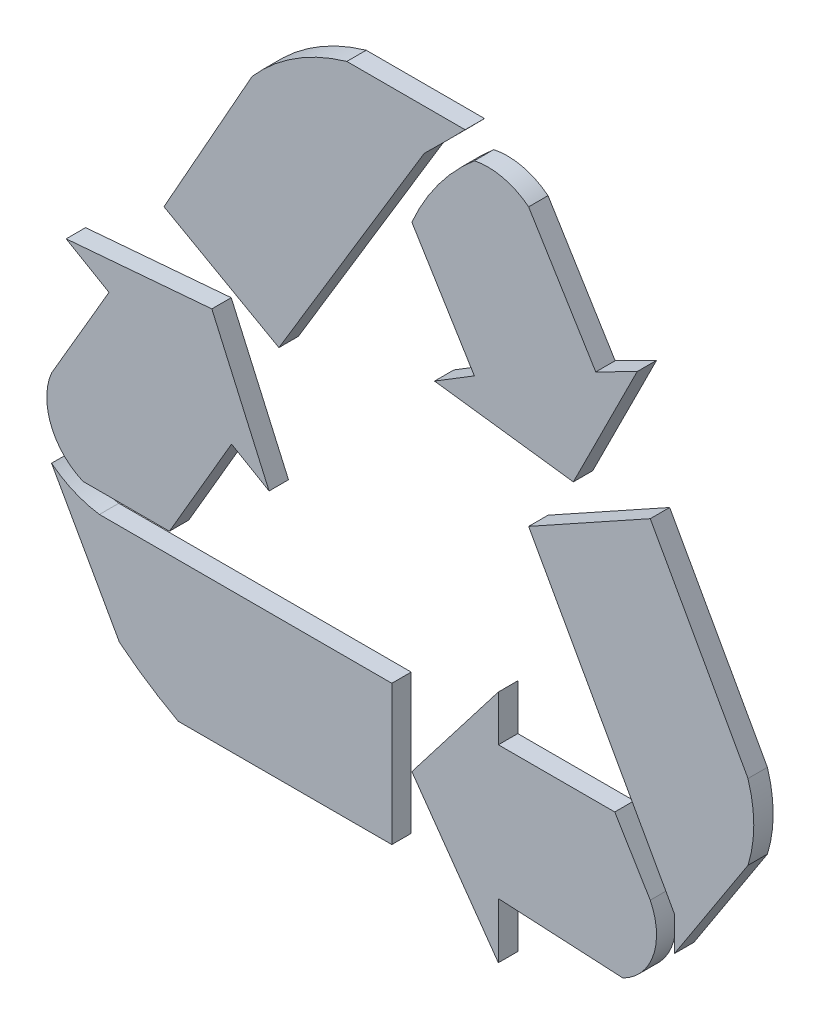
from build123d import *

# Parameters (mm, degrees)
BOSS_EXTRUDE1_DEPTH   = 0.254
BOSS_EXTRUDE1_2_DEPTH = 0.254
BOSS_EXTRUDE1_3_DEPTH = 0.254
BOSS_EXTRUDE1_4_DEPTH = 0.254
BOSS_EXTRUDE1_5_DEPTH = 0.254
BOSS_EXTRUDE1_6_DEPTH = 0.254


with BuildPart() as part:
    # Sketch1 → Boss-Extrude1 (new body)
    with BuildSketch(Plane.XY):
        with BuildLine():
            Line((5.637000935, 11.943781458), (7.185995863, 11.943781458))
            ThreePointArc((7.185995863, 11.943781458), (6.919891183, 11.674778799), (6.650888524, 11.408674119))
            Line((6.650888524, 11.408674119), (4.747952976, 8.254071924))
            Line((4.747952976, 8.254071924), (3.243099683, 9.0992635))
            Line((3.243099683, 9.0992635), (4.397804993, 11.155202222))
            ThreePointArc((4.397804993, 11.155202222), (4.960721662, 11.638562457), (5.637000935, 11.943781458))
        make_face()
    extrude(amount=BOSS_EXTRUDE1_DEPTH)


with BuildPart() as body_2:
    # Sketch1 → Boss-Extrude1 2 (new body)
    with BuildSketch(Plane.XY):
        with BuildLine():
            Line((6.48874249, 10.5468587), (7.307105521, 9.213267603))
            Line((7.307105521, 9.213267603), (6.785548208, 8.893212059))
            Line((6.785548208, 8.893212059), (8.603076052, 8.658733216))
            Line((8.603076052, 8.658733216), (9.439062626, 10.328298615))
            Line((9.439062626, 10.328298615), (8.89668655, 10.052613091))
            Line((8.89668655, 10.052613091), (8.017649291, 11.485077924))
            ThreePointArc((8.017649291, 11.485077924), (7.681060328, 11.64807643), (7.307105521, 11.652371198))
            ThreePointArc((7.307105521, 11.652371198), (6.834746968, 11.146382174), (6.48874249, 10.5468587))
        make_face()
    extrude(amount=BOSS_EXTRUDE1_2_DEPTH)


with BuildPart() as body_3:
    # Sketch1 → Boss-Extrude1 3 (new body)
    with BuildSketch(Plane.XY):
        with BuildLine():
            Line((8.017649291, 7.861746009), (9.610046163, 8.745368466))
            Line((9.610046163, 8.745368466), (10.889800345, 6.439093267))
            ThreePointArc((10.889800345, 6.439093267), (10.965604743, 5.946852431), (10.889800345, 5.454611596))
            Line((10.889800345, 5.454611596), (9.927748084, 3.973263118))
            Line((9.927748084, 3.973263118), (9.927748084, 4.419511916))
            Line((9.927748084, 4.419511916), (8.017649291, 7.861746009))
        make_face()
    extrude(amount=BOSS_EXTRUDE1_3_DEPTH)


with BuildPart() as body_4:
    # Sketch1 → Boss-Extrude1 4 (new body)
    with BuildSketch(Plane.XY):
        with BuildLine():
            Line((7.621464325, 5.187129092), (9.145128923, 5.187129092))
            Line((9.145128923, 5.187129092), (9.610046163, 4.419511916))
            ThreePointArc((9.610046163, 4.419511916), (9.650762974, 3.814407191), (9.251680452, 3.357742403))
            Line((9.251680452, 3.357742403), (7.621464325, 3.443237722))
            Line((7.621464325, 3.443237722), (7.621464325, 2.715572638))
            Line((7.621464325, 2.715572638), (6.48874249, 4.316477857))
            Line((6.48874249, 4.316477857), (7.621464325, 5.785785902))
            Line((7.621464325, 5.785785902), (7.621464325, 5.187129092))
        make_face()
    extrude(amount=BOSS_EXTRUDE1_4_DEPTH)


with BuildPart() as body_5:
    # Sketch1 → Boss-Extrude1 5 (new body)
    with BuildSketch(Plane.XY):
        with BuildLine():
            Line((1.962512056, 8.094982994), (3.869542298, 8.254071924))
            Line((3.869542298, 8.254071924), (4.619508312, 6.563952326))
            Line((4.619508312, 6.563952326), (4.12815791, 6.850481717))
            Line((4.12815791, 6.850481717), (3.314160785, 5.454611596))
            Line((3.314160785, 5.454611596), (2.182778024, 5.454611596))
            ThreePointArc((2.182778024, 5.454611596), (1.764914266, 5.881076175), (1.770995964, 6.478106467))
            Line((1.770995964, 6.478106467), (2.523203463, 7.768017622))
            Line((2.523203463, 7.768017622), (1.962512056, 8.094982994))
        make_face()
    extrude(amount=BOSS_EXTRUDE1_5_DEPTH)


with BuildPart() as body_6:
    # Sketch1 → Boss-Extrude1 6 (new body)
    with BuildSketch(Plane.XY):
        with BuildLine():
            Line((6.226223733, 5.187129092), (6.226223733, 3.357742403))
            Line((6.226223733, 3.357742403), (3.430797167, 3.357742403))
            ThreePointArc((3.430797167, 3.357742403), (3.03357937, 3.595122118), (2.660195359, 3.868463459))
            Line((2.660195359, 3.868463459), (1.770995964, 5.454611596))
            ThreePointArc((1.770995964, 5.454611596), (2.066843427, 5.279302969), (2.398148139, 5.187129092))
            Line((2.398148139, 5.187129092), (6.226223733, 5.187129092))
        make_face()
    extrude(amount=BOSS_EXTRUDE1_6_DEPTH)


solid = Compound([part.part, body_2.part, body_3.part, body_4.part, body_5.part, body_6.part])
